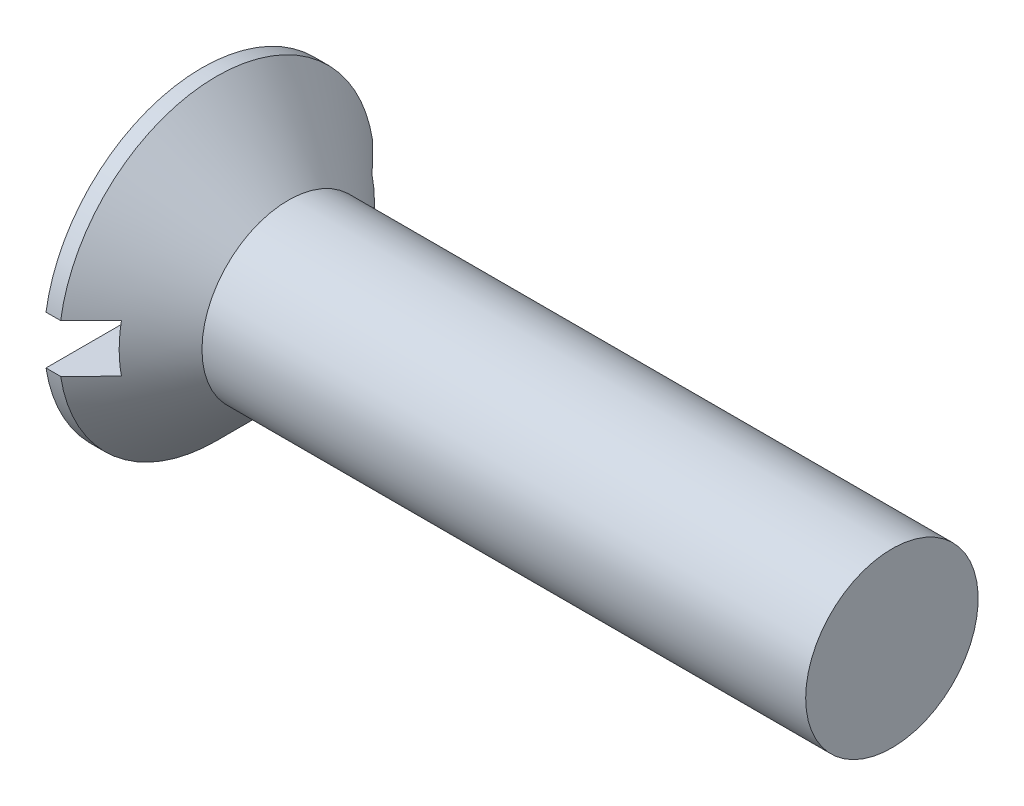
from build123d import *

# Parameters (mm, degrees)
SKETCH2_W         = 18.3
SKETCH2_H         = 2.8
SLOT_DEPTH        = 2.6
SKETCH3_W         = 1.98
SKETCH3_H         = 9.88
SKETCH4_W         = 0.99
SKETCH4_H         = 0.99
CIRPATTERN1_COUNT = 2
CIRPATTERN1_ANGLE = 90


with BuildPart() as part:
    # BodySke → Base-Revolve (revolve)
    with BuildSketch(Plane.XY):
        Polygon((0, 0), (0, 9.15), (0.85, 9.15), (5, 5), (40, 5), (40, 0), align=None)
    revolve(axis=Axis((-6.35, 0, 0), (1, 0, 0)))

    # Sketch2 → Slot (cut)
    with BuildSketch(Plane.ZY):
        Rectangle(SKETCH2_W, SKETCH2_H)
    extrude(amount=-SLOT_DEPTH, mode=Mode.SUBTRACT)

    # Sketch3 → Cross section 0
    with BuildSketch(Plane.ZY):
        Rectangle(SKETCH3_W, SKETCH3_H)
    # Sketch4 → Cross section 1
    with BuildSketch(Plane.ZY.offset(-5.98)):
        Rectangle(SKETCH4_W, SKETCH4_H)
    cross = loft(mode=Mode.SUBTRACT)

    # CirPattern1: Cross ×2 about axis
    cirpattern1_axis = Axis((0, 0, 0), (1, 0, 0))
    for i in range(1, CIRPATTERN1_COUNT):
        add(cross.rotate(cirpattern1_axis, i * CIRPATTERN1_ANGLE / (CIRPATTERN1_COUNT - 1)), mode=Mode.SUBTRACT)


solid = part.part
